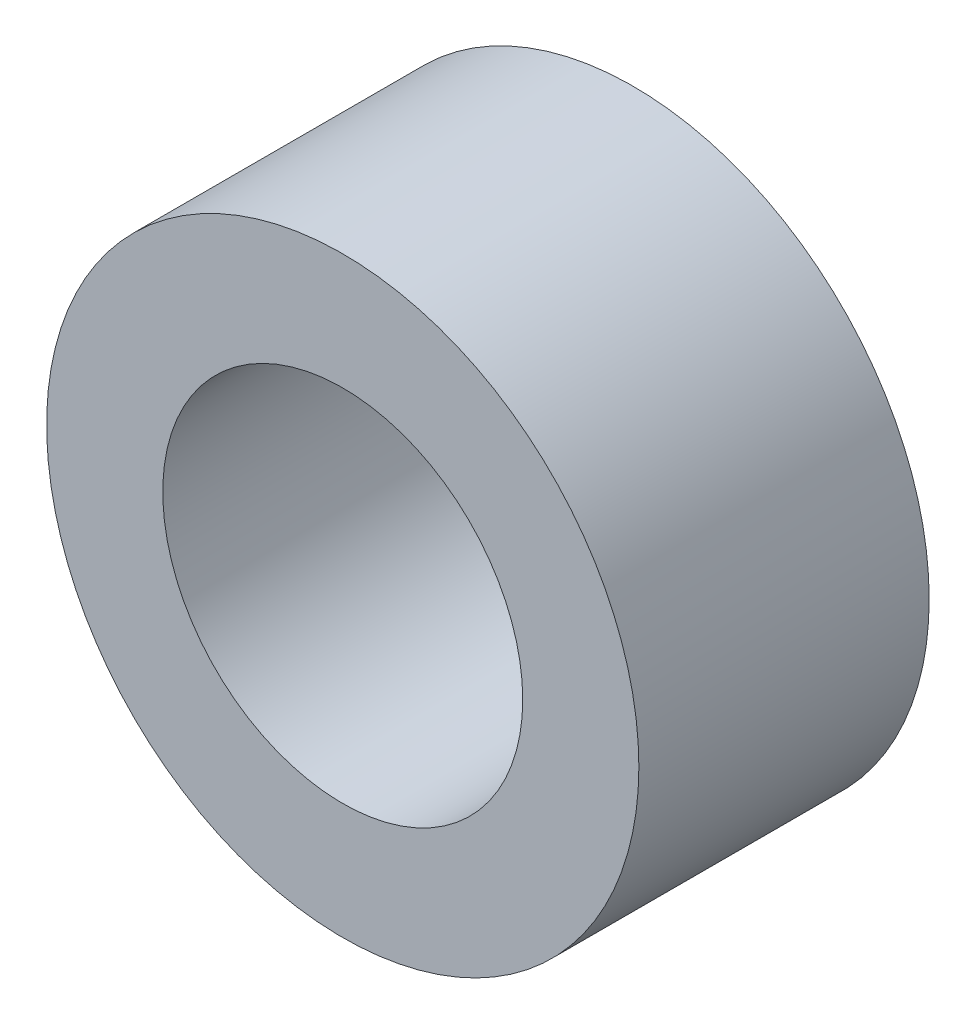
from build123d import *

# Parameters (mm, degrees)
SKETCH1_R           = 10.2
SKETCH1_R_2         = 6.2
BOSS_EXTRUDE1_DEPTH = 10


with BuildPart() as part:
    # Sketch1 → Boss-Extrude1 (new body)
    with BuildSketch(Plane.XY):
        Circle(SKETCH1_R)
        Circle(SKETCH1_R_2, mode=Mode.SUBTRACT)
    extrude(amount=BOSS_EXTRUDE1_DEPTH)


solid = part.part
